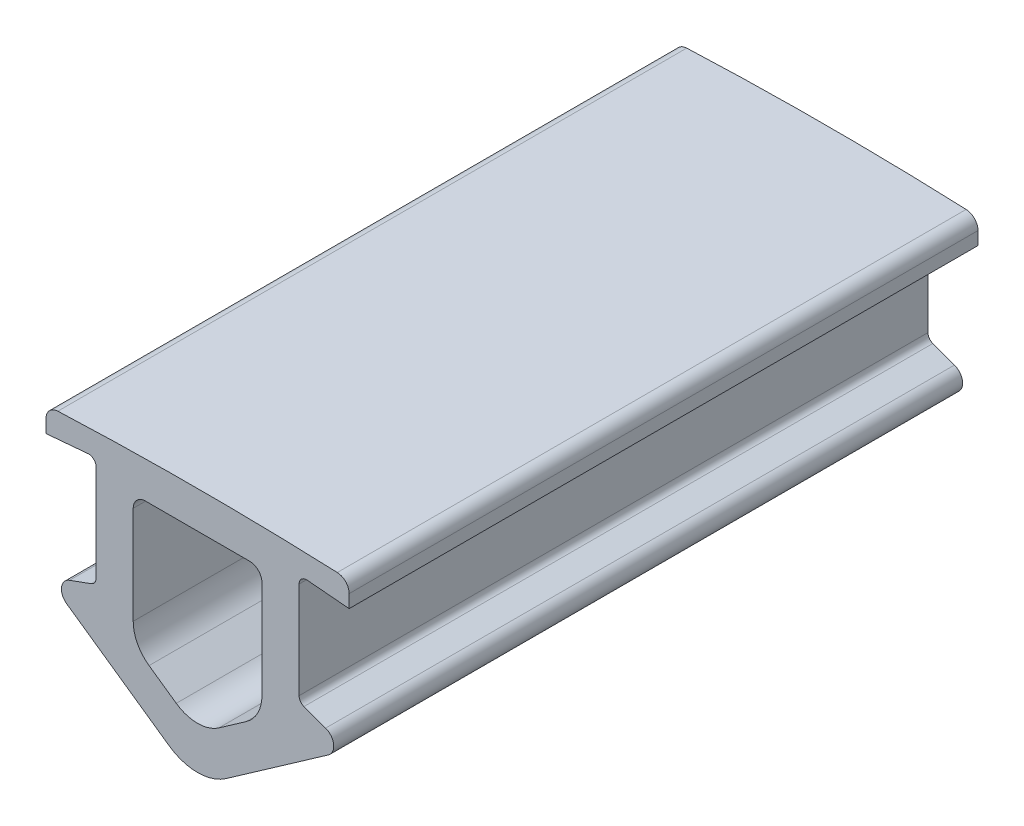
from build123d import *

# Parameters (mm, degrees)
EXTRUSION4_DEPTH = 25.4


with BuildPart() as part:
    # Sketch1 → Extrusion4 (new body)
    with BuildSketch(Plane.XY):
        with BuildLine():
            ThreePointArc((5.643340731, 1.02471553), (5e-09, 1.14270907), (-5.643340721, 1.02471553))
            ThreePointArc((-5.643340721, 1.02471553), (-5.983308169, 0.871238001), (-6.12244139, 0.525152514))
            Line((-6.12244139, 0.525152514), (-6.12244139, 0))
            Line((-6.12244139, 0), (-4.426152829, 0.148406019))
            ThreePointArc((-4.426152829, 0.148406019), (-4.197329039, 0.070730809), (-4.1000061, -0.150452395))
            Line((-4.1000061, -0.150452395), (-4.1000061, -4.055821252))
            ThreePointArc((-4.1000061, -4.055821252), (-4.154260478, -4.227894187), (-4.297400051, -4.337729045))
            Line((-4.297400051, -4.337729045), (-5.171010065, -4.655697092))
            ThreePointArc((-5.171010065, -4.655697092), (-5.495722421, -5.060280306), (-5.286788207, -5.535119422))
            Line((-5.286788207, -5.535119422), (-1.147152857, -8.433723282))
            ThreePointArc((-1.147152857, -8.433723282), (1e-08, -8.79541919), (1.147152877, -8.433723282))
            Line((1.147152877, -8.433723282), (5.286788227, -5.535119422))
            ThreePointArc((5.286788227, -5.535119422), (5.495722441, -5.060280306), (5.171010085, -4.655697092))
            Line((5.171010085, -4.655697092), (4.297400071, -4.337729045))
            ThreePointArc((4.297400071, -4.337729045), (4.154260498, -4.227894187), (4.10000611, -4.055821252))
            Line((4.10000611, -4.055821252), (4.10000611, -0.15045238))
            ThreePointArc((4.10000611, -0.15045238), (4.197329045, 0.070730814), (4.426152823, 0.148406021))
            Line((4.426152823, 0.148406021), (6.1224414, 0))
            Line((6.1224414, 0), (6.1224414, 0.525152514))
            ThreePointArc((6.1224414, 0.525152514), (5.983308179, 0.871238001), (5.643340731, 1.02471553))
        make_face()
        with BuildLine():
            ThreePointArc((-2.100006108, -0.35045215), (-2.4535595, -0.49689876), (-2.60000611, -0.850452152))
            Line((-2.60000611, -0.850452152), (-2.60000611, -4.804412051))
            ThreePointArc((-2.60000611, -4.804412051), (-2.430522356, -5.497034977), (-1.960370752, -6.033140126))
            Line((-1.960370752, -6.033140126), (-0.860364633, -6.803372685))
            ThreePointArc((-0.860364633, -6.803372685), (2e-08, -7.07464461), (0.860364668, -6.803372674))
            Line((0.860364668, -6.803372674), (1.960370758, -6.033140115))
            ThreePointArc((1.960370758, -6.033140115), (2.430522351, -5.497034969), (2.6000061, -4.804412051))
            Line((2.6000061, -4.804412051), (2.6000061, -0.850452152))
            ThreePointArc((2.6000061, -0.850452152), (2.45355949, -0.49689876), (2.100006098, -0.35045215))
            Line((2.100006098, -0.35045215), (-2.100006108, -0.35045215))
        make_face(mode=Mode.SUBTRACT)
    extrude(amount=EXTRUSION4_DEPTH)


solid = part.part
